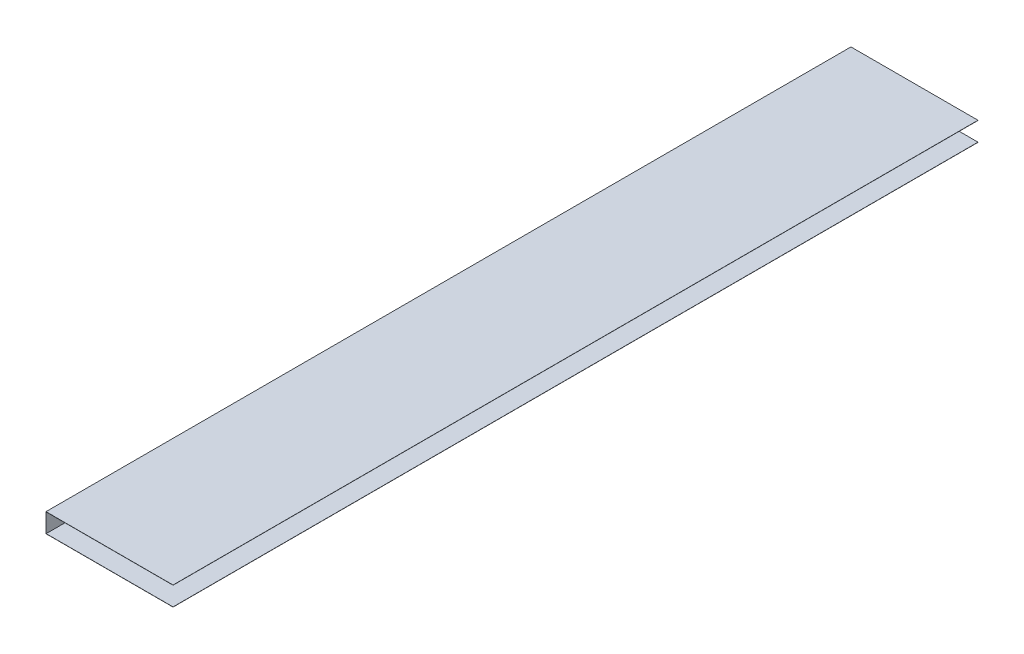
from build123d import *

# Parameters (mm, degrees)
BOSS_EXTRUDE1_DEPTH = 925


with BuildPart() as part:
    # Sketch1 → Boss-Extrude1 (new body)
    with BuildSketch(Plane.XY):
        Polygon((0, 0), (146, 0), (146, -0.2), (0.2, -0.2), (0.2, -21.8), (146, -21.8), (146, -22), (0, -22), align=None)
    extrude(amount=BOSS_EXTRUDE1_DEPTH)


solid = part.part
